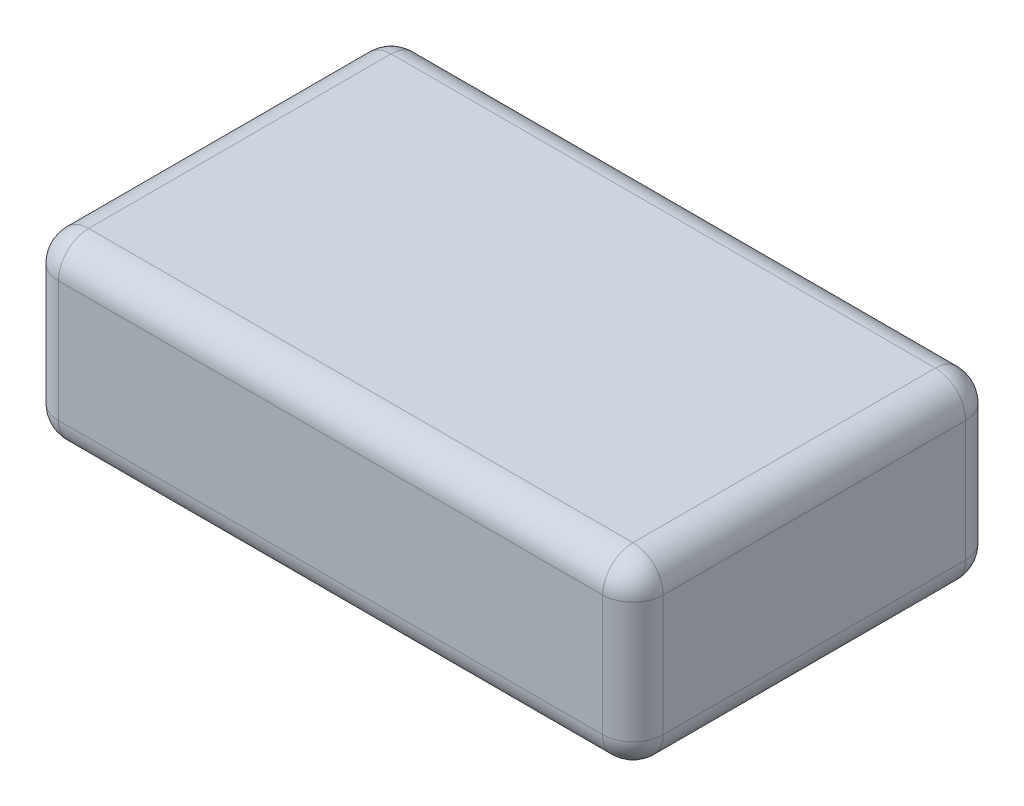
from build123d import *

# Parameters (mm, degrees)
SKETCH1_W           = 63.5
SKETCH1_H           = 38.1
BOSS_EXTRUDE1_DEPTH = 19.05
FILLET1_R           = 3.175


with BuildPart() as part:
    # Sketch1 → Boss-Extrude1 (new body)
    with BuildSketch(Plane(origin=(0, 0, 0), x_dir=(1, 0, 0), z_dir=(0, 1, 0))):
        Rectangle(SKETCH1_W, SKETCH1_H)
    extrude(amount=BOSS_EXTRUDE1_DEPTH)

    # Fillet1
    fillet1_edges = [part.edges().sort_by_distance(p)[0] for p in [
        (-31.75, 19.05, 0),
        (0, 19.05, 19.05),
        (31.75, 19.05, 0),
        (0, 0, 19.05),
        (-31.75, 0, 0),
        (0, 0, -19.05),
        (31.75, 0, 0),
        (31.75, 9.525, 19.05),
        (-31.75, 9.525, 19.05),
        (-31.75, 9.525, -19.05),
        (31.75, 9.525, -19.05),
        (0, 19.05, -19.05),
    ]]
    fillet(fillet1_edges, radius=FILLET1_R)


solid = part.part
